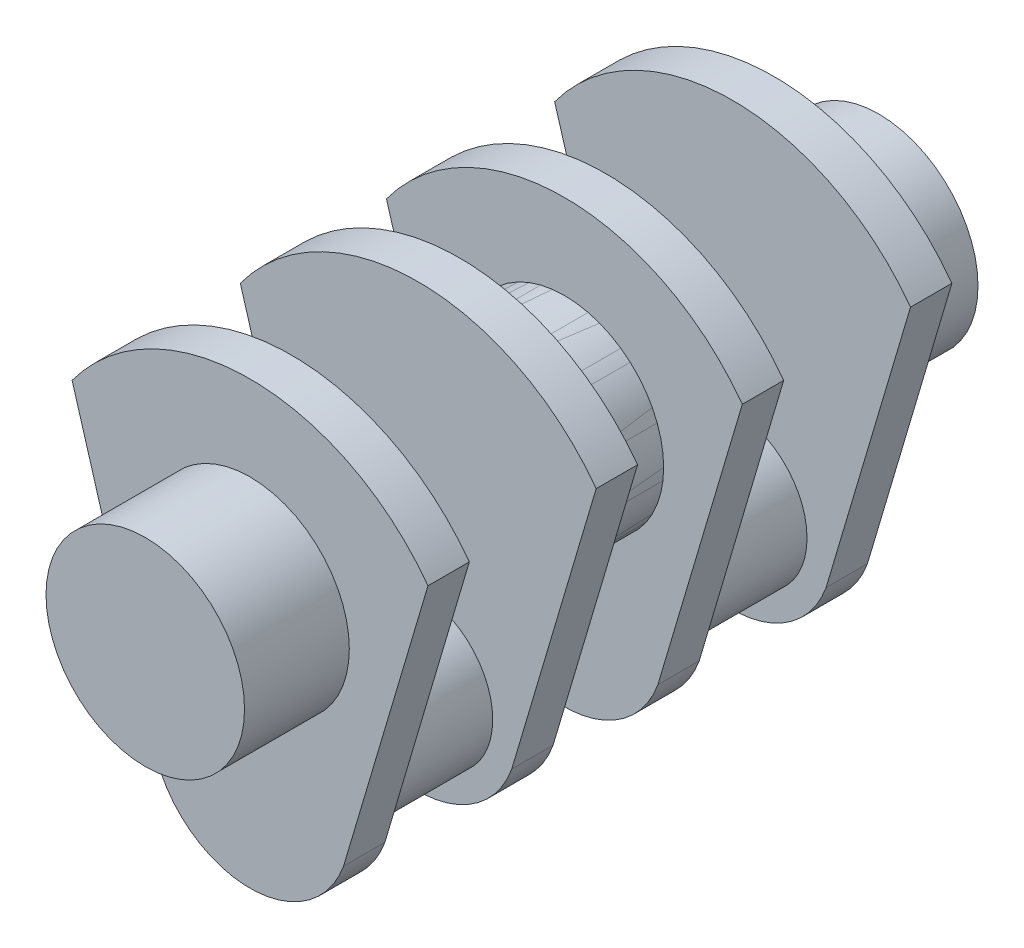
from build123d import *

# Parameters (mm, degrees)
BOSS_EXTRUDE1_DEPTH = 381
SKETCH3_R           = 685.8
BOSS_EXTRUDE2_DEPTH = 1168.4
SKETCH4_R           = 914.4
BOSS_EXTRUDE3_DEPTH = 965.2


with BuildPart() as part:
    # Sketch2 → Boss-Extrude1 (new body)
    with BuildSketch(Plane.XY):
        with BuildLine():
            ThreePointArc((1639.073881445, 865.438888575), (0, 1696.413988265), (-1639.073881445, 865.438888575))
            Line((-1639.073881445, 865.438888575), (-889.551566195, -1664.906041679))
            ThreePointArc((-889.551566195, -1664.906041679), (-106.586602983, -545.019366199), (914.4, -1453.186011735))
            ThreePointArc((914.4, -1453.186011735), (908.166645536, -1559.772614718), (889.551566195, -1664.906041679))
            Line((889.551566195, -1664.906041679), (1639.073881445, 865.438888575))
        make_face()
        with BuildLine():
            ThreePointArc((914.4, -1453.186011735), (-106.586602983, -545.019366199), (-889.551566195, -1664.906041679))
            Line((-889.551566195, -1664.906041679), (-861.35171004, -1760.107160586))
            ThreePointArc((-861.35171004, -1760.107160586), (0, -2367.586011735), (861.35171004, -1760.107160586))
            Line((861.35171004, -1760.107160586), (889.551566195, -1664.906041679))
            ThreePointArc((889.551566195, -1664.906041679), (908.166645536, -1559.772614718), (914.4, -1453.186011735))
        make_face()
    extrude(amount=BOSS_EXTRUDE1_DEPTH)

    # Sketch3 → Boss-Extrude2 (add)
    with BuildSketch(Plane(origin=(0, 0, 0), x_dir=(-1, 0, 0), z_dir=(0, 0, -1))):
        with Locations((0, -1453.186011735)):
            Circle(SKETCH3_R)
    extrude(amount=BOSS_EXTRUDE2_DEPTH)

    # Sketch4 → Boss-Extrude3 (add)
    with BuildSketch(Plane.XY.offset(381)):
        Circle(SKETCH4_R)
    extrude(amount=BOSS_EXTRUDE3_DEPTH)

    # Mirror1: part across plane


with BuildPart() as part_1:
    add(part.part)
    add(part.part.mirror(Plane(origin=(0, 0, -584.2), x_dir=(1, 0, 0), z_dir=(0, 0, -1))))


with BuildPart() as body_2:
    # Mirror2: mirrored copy
    add(part_1.part.mirror(Plane(origin=(0, 0, -2032), x_dir=(1, 0, 0), z_dir=(0, 0, -1))))


solid = Compound([part_1.part, body_2.part])
